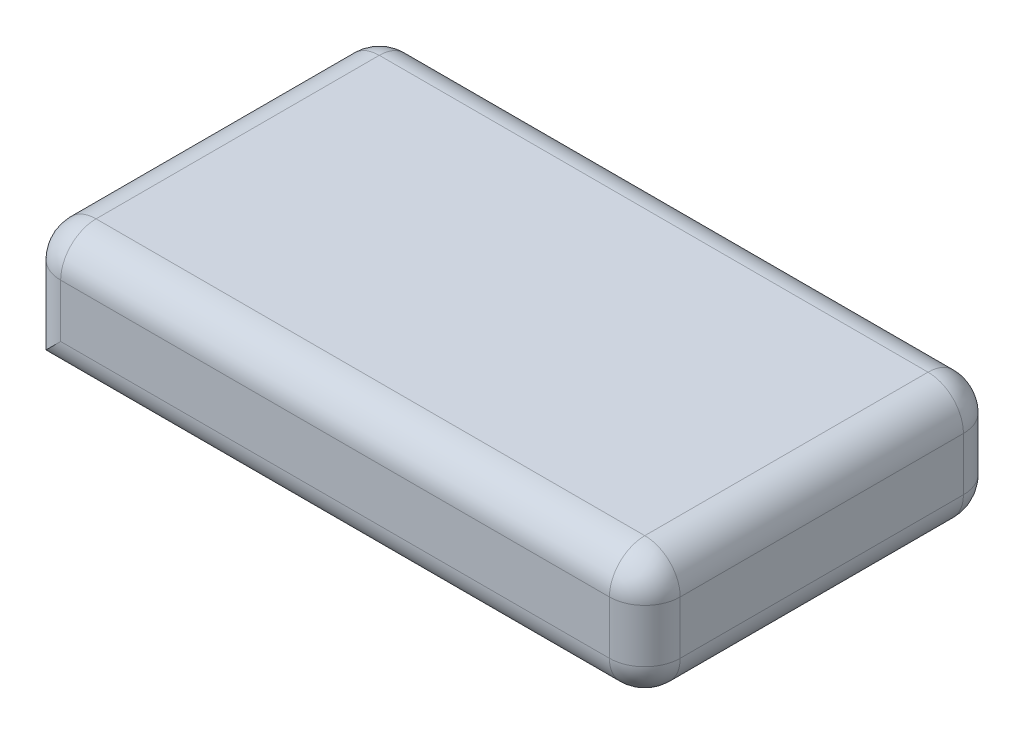
from build123d import *

# Parameters (mm, degrees)
CROQUIS1_W              = 35
CROQUIS1_H              = 20
SALIENTE_EXTRUIR1_DEPTH = 7
REDONDEO1_R             = 2


with BuildPart() as part:
    # Croquis1 → Saliente-Extruir1 (new body)
    with BuildSketch(Plane(origin=(0, 0, 0), x_dir=(1, 0, 0), z_dir=(0, 1, 0))):
        Rectangle(CROQUIS1_W, CROQUIS1_H)
    extrude(amount=SALIENTE_EXTRUIR1_DEPTH)

    # Redondeo1
    redondeo1_edges = [part.edges().sort_by_distance(p)[0] for p in [
        (-17.5, 7, 0),
        (0, 7, 10),
        (17.5, 7, 0),
        (0, 0, 10),
        (0, 0, -10),
        (17.5, 0, 0),
        (0, 7, -10),
        (17.5, 3.5, 10),
        (-17.5, 3.5, 10),
        (-17.5, 3.5, -10),
        (17.5, 3.5, -10),
    ]]
    fillet(redondeo1_edges, radius=REDONDEO1_R)


solid = part.part
